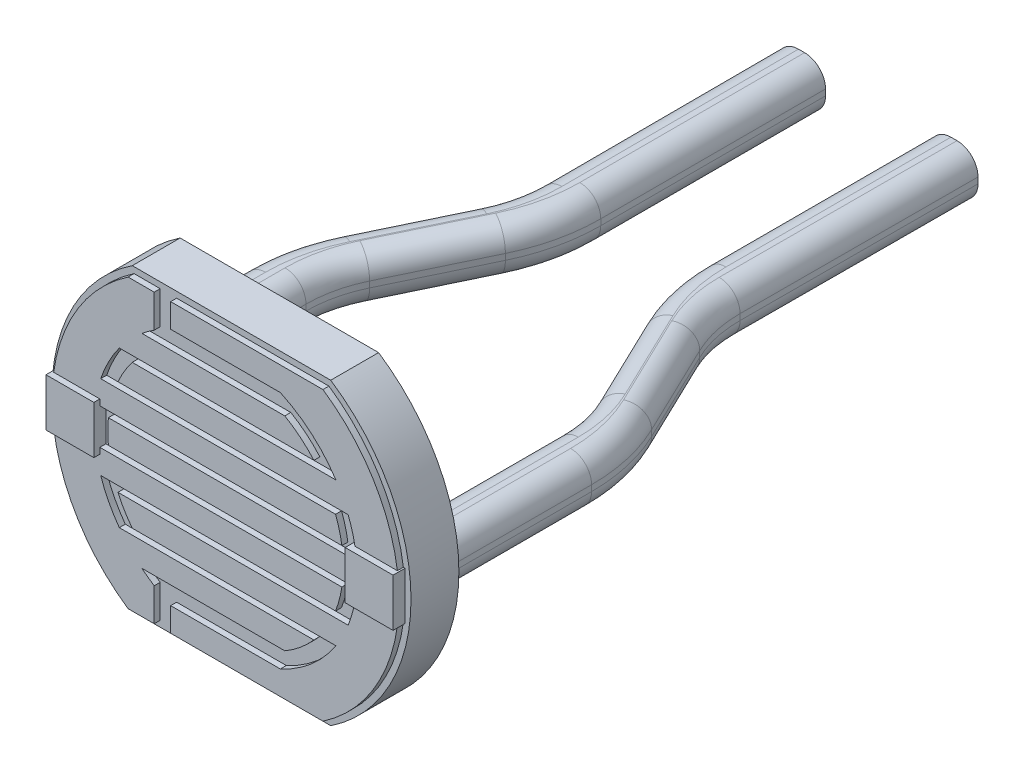
from build123d import *

# Parameters (mm, degrees)
BASE_EXTRUSION_DEPTH = 0.8
BOSS_EXTRU_1_DEPTH   = 0.1
BOSS_EXTRU_2_DEPTH   = 0.4
CONG_1_R             = 0.35


with BuildPart() as part:
    # Esquisse1 → Base-Extrusion (new body)
    with BuildSketch(Plane.XY):
        with BuildLine():
            Line((-1.658312395, 2.5), (1.658312395, 2.5))
            ThreePointArc((1.658312395, 2.5), (3, 0), (1.658312395, -2.5))
            Line((1.658312395, -2.5), (-1.658312395, -2.5))
            ThreePointArc((-1.658312395, -2.5), (-3, 0), (-1.658312395, 2.5))
        make_face()
    extrude(amount=BASE_EXTRUSION_DEPTH)

    # Esquisse2 → Boss.-Extru.1 (add)
    with BuildSketch(Plane.XY.offset(0.8)):
        with BuildLine():
            Line((-0.916515139, -2.4), (1.62788206, -2.4))
            ThreePointArc((1.62788206, -2.4), (2.9, 0), (1.62788206, 2.4))
            Line((1.62788206, 2.4), (-0.916515139, 2.4))
            Line((-0.916515139, 2.4), (-0.916515139, 2))
            Line((-0.916515139, 2), (0.916515139, 2))
            ThreePointArc((0.916515139, 2), (1.437005639, 1.665837565), (1.843908891, 1.2))
            Line((1.843908891, 1.2), (-1.559235883, 1.2))
            ThreePointArc((-1.559235883, 1.2), (-1.690271317, 1.007074683), (-1.797558494, 0.8))
            Line((-1.797558494, 0.8), (2.049390153, 0.8))
            ThreePointArc((2.049390153, 0.8), (2.14126001, 0.50498076), (2.19089023, 0.2))
            Line((2.19089023, 0.2), (-1.957349366, 0.2))
            ThreePointArc((-1.957349366, 0.2), (-1.967540734, 0), (-1.957349366, -0.2))
            Line((-1.957349366, -0.2), (2.19089023, -0.2))
            ThreePointArc((2.19089023, -0.2), (2.14126001, -0.50498076), (2.049390153, -0.8))
            Line((2.049390153, -0.8), (-1.797558494, -0.8))
            ThreePointArc((-1.797558494, -0.8), (-1.690271317, -1.007074683), (-1.559235883, -1.2))
            Line((-1.559235883, -1.2), (1.843908891, -1.2))
            ThreePointArc((1.843908891, -1.2), (1.437005639, -1.665837565), (0.916515139, -2))
            Line((0.916515139, -2), (-0.916515139, -2))
            Line((-0.916515139, -2), (-0.916515139, -2.4))
        make_face()
        with BuildLine():
            Line((-1.191577163, -1.849363097), (-1.191577163, -2.4))
            Line((-1.191577163, -2.4), (-1.62788206, -2.4))
            ThreePointArc((-1.62788206, -2.4), (-2.9, 0), (-1.62788206, 2.4))
            Line((-1.62788206, 2.4), (-1.191577163, 2.4))
            Line((-1.191577163, 2.4), (-1.191577163, 1.849363097))
            ThreePointArc((-1.191577163, 1.849363097), (-1.296153866, 1.777634708), (-1.396424004, 1.7))
            Line((-1.396424004, 1.7), (0.990563749, 1.7))
            ThreePointArc((0.990563749, 1.7), (1.249834872, 1.51958196), (1.476894221, 1.3))
            Line((1.476894221, 1.3), (-1.774823935, 1.3))
            ThreePointArc((-1.774823935, 1.3), (-1.953418645, 1.01200573), (-2.085665361, 0.7))
            Line((-2.085665361, 0.7), (1.838808457, 0.7))
            ThreePointArc((1.838808457, 0.7), (1.902215028, 0.502786762), (1.944535045, 0.3))
            Line((1.944535045, 0.3), (-2.179449472, 0.3))
            ThreePointArc((-2.179449472, 0.3), (-2.2, 0), (-2.179449472, -0.3))
            Line((-2.179449472, -0.3), (1.944535045, -0.3))
            ThreePointArc((1.944535045, -0.3), (1.902215028, -0.502786762), (1.838808457, -0.7))
            Line((1.838808457, -0.7), (-2.085665361, -0.7))
            ThreePointArc((-2.085665361, -0.7), (-1.953418645, -1.01200573), (-1.774823935, -1.3))
            Line((-1.774823935, -1.3), (1.476894221, -1.3))
            ThreePointArc((1.476894221, -1.3), (1.249834872, -1.51958196), (0.990563749, -1.7))
            Line((0.990563749, -1.7), (-1.396424004, -1.7))
            ThreePointArc((-1.396424004, -1.7), (-1.296153866, -1.777634708), (-1.191577163, -1.849363097))
        make_face()
    extrude(amount=BOSS_EXTRU_1_DEPTH)

    # Esquisse11 → Boss.-Extru.2 (add, symmetric)
    with BuildSketch(Plane(origin=(0, 0, 0), x_dir=(1, 0, 0), z_dir=(0, 1, 0))):
        with BuildLine():
            Line((-1.675077348, 10), (-0.872636816, 10))
            Line((-0.872636816, 10), (-0.87164609, 6.242574189))
            ThreePointArc((-0.87164609, 6.242574189), (-0.946348213, 5.576476525), (-1.167076814, 4.943589972))
            Line((-1.167076814, 4.943589972), (-1.903046115, 3.410320594))
            ThreePointArc((-1.903046115, 3.410320594), (-2.050140024, 2.988653327), (-2.1, 2.544858459))
            Line((-2.1, 2.544858459), (-2.1, -1))
            Line((-2.1, -1), (-2.9, -1))
            Line((-2.9, -1), (-2.9, 2.317287688))
            ThreePointArc((-2.9, 2.317287688), (-2.825210037, 2.98297999), (-2.604569172, 3.615480891))
            Line((-2.604569172, 3.615480891), (-1.861434096, 5.163678966))
            ThreePointArc((-1.861434096, 5.163678966), (-1.713749345, 5.587950568), (-1.664487343, 6.034482127))
            Line((-1.664487343, 6.034482127), (-1.675077348, 10))
        make_face()
        with BuildLine():
            Line((1.675077348, 10), (0.872636816, 10))
            Line((0.872636816, 10), (0.87164609, 6.242574189))
            ThreePointArc((0.87164609, 6.242574189), (0.946348213, 5.576476525), (1.167076814, 4.943589972))
            Line((1.167076814, 4.943589972), (1.903046115, 3.410320594))
            ThreePointArc((1.903046115, 3.410320594), (2.050140024, 2.988653327), (2.1, 2.544858459))
            Line((2.1, 2.544858459), (2.1, -1))
            Line((2.1, -1), (2.9, -1))
            Line((2.9, -1), (2.9, 2.317287688))
            ThreePointArc((2.9, 2.317287688), (2.825210037, 2.98297999), (2.604569172, 3.615480891))
            Line((2.604569172, 3.615480891), (1.861434096, 5.163678966))
            ThreePointArc((1.861434096, 5.163678966), (1.713749345, 5.587950568), (1.664487343, 6.034482127))
            Line((1.664487343, 6.034482127), (1.675077348, 10))
        make_face()
    extrude(amount=BOSS_EXTRU_2_DEPTH, both=True)

    # Congé1
    cong_1_edges = [part.edges().sort_by_distance(p)[0] for p in [
        (-2.9, -0.4, -1.158643844),
        (-2.1, -0.4, -1.272429229),
        (-2.1, 0.4, -1.272429229),
        (-2.050140024, 0.4, -2.988653327),
        (-1.535061464, 0.4, -4.176955283),
        (-0.946348213, 0.4, -5.576476525),
        (-0.872141453, 0.4, -8.121287094),
        (-1.669782345, 0.4, -8.017241064),
        (-1.713749345, 0.4, -5.587950568),
        (-2.233001634, 0.4, -4.389579928),
        (-2.825210037, 0.4, -2.98297999),
        (-2.9, 0.4, -1.158643844),
        (-2.050140024, -0.4, -2.988653327),
        (-1.535061464, -0.4, -4.176955283),
        (-0.946348213, -0.4, -5.576476525),
        (-0.872141453, -0.4, -8.121287094),
        (-1.669782345, -0.4, -8.017241064),
        (-1.713749345, -0.4, -5.587950568),
        (-2.233001634, -0.4, -4.389579928),
        (-2.825210037, -0.4, -2.98297999),
        (2.1, -0.4, -1.272429229),
        (2.9, -0.4, -1.158643844),
        (2.9, 0.4, -1.158643844),
        (2.825210037, 0.4, -2.98297999),
        (2.233001634, 0.4, -4.389579928),
        (1.713749345, 0.4, -5.587950568),
        (1.669782345, 0.4, -8.017241064),
        (0.872141453, 0.4, -8.121287094),
        (0.946348213, 0.4, -5.576476525),
        (1.535061464, 0.4, -4.176955283),
        (2.050140024, 0.4, -2.988653327),
        (2.1, 0.4, -1.272429229),
        (1.669782345, -0.4, -8.017241064),
        (0.872141453, -0.4, -8.121287094),
        (0.946348213, -0.4, -5.576476525),
        (1.535061464, -0.4, -4.176955283),
        (2.050140024, -0.4, -2.988653327),
        (2.825210037, -0.4, -2.98297999),
        (2.233001634, -0.4, -4.389579928),
        (1.713749345, -0.4, -5.587950568),
    ]]
    fillet(cong_1_edges, radius=CONG_1_R)


solid = part.part
